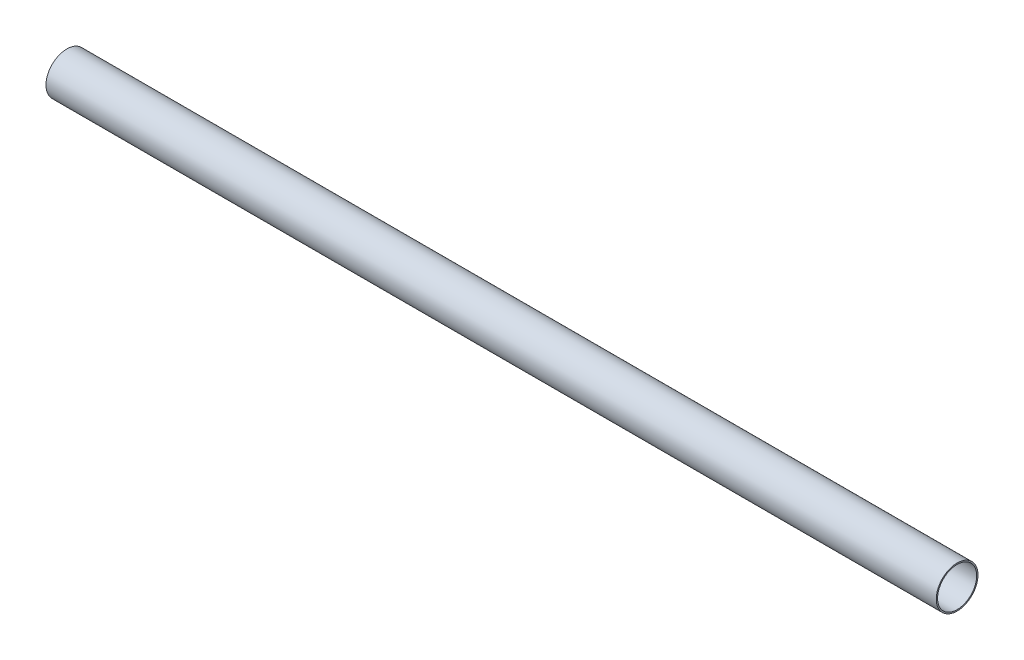
from build123d import *

# Parameters (mm, degrees)
SKETCH1_R      = 14.2875
SKETCH1_R_2    = 13.3985
EXTRUDE1_DEPTH = 304.8


with BuildPart() as part:
    # Sketch1 → Extrude1 (new body, symmetric)
    with BuildSketch(Plane(origin=(0, 0, 0), x_dir=(0, 0, -1), z_dir=(1, 0, 0))):
        Circle(SKETCH1_R)
        Circle(SKETCH1_R_2, mode=Mode.SUBTRACT)
    extrude(amount=EXTRUDE1_DEPTH, both=True)


solid = part.part
